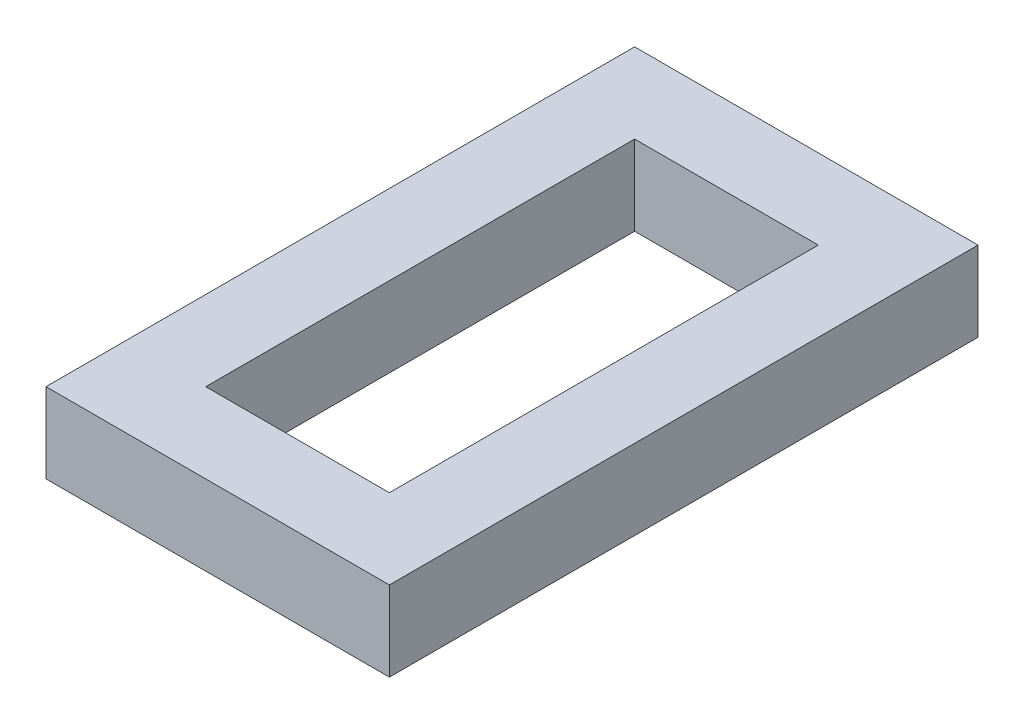
from build123d import *

# Parameters (mm, degrees)
SKETCH1_W           = 68.25
SKETCH1_H           = 117
SKETCH1_W_2         = 36.5
SKETCH1_H_2         = 85.25
BOSS_EXTRUDE1_DEPTH = 15.875


with BuildPart() as part:
    # Sketch1 → Boss-Extrude1 (new body)
    with BuildSketch(Plane(origin=(0, 0, 0), x_dir=(1, 0, 0), z_dir=(0, 1, 0))):
        Rectangle(SKETCH1_W, SKETCH1_H)
        Rectangle(SKETCH1_W_2, SKETCH1_H_2, mode=Mode.SUBTRACT)
    extrude(amount=BOSS_EXTRUDE1_DEPTH)


solid = part.part
